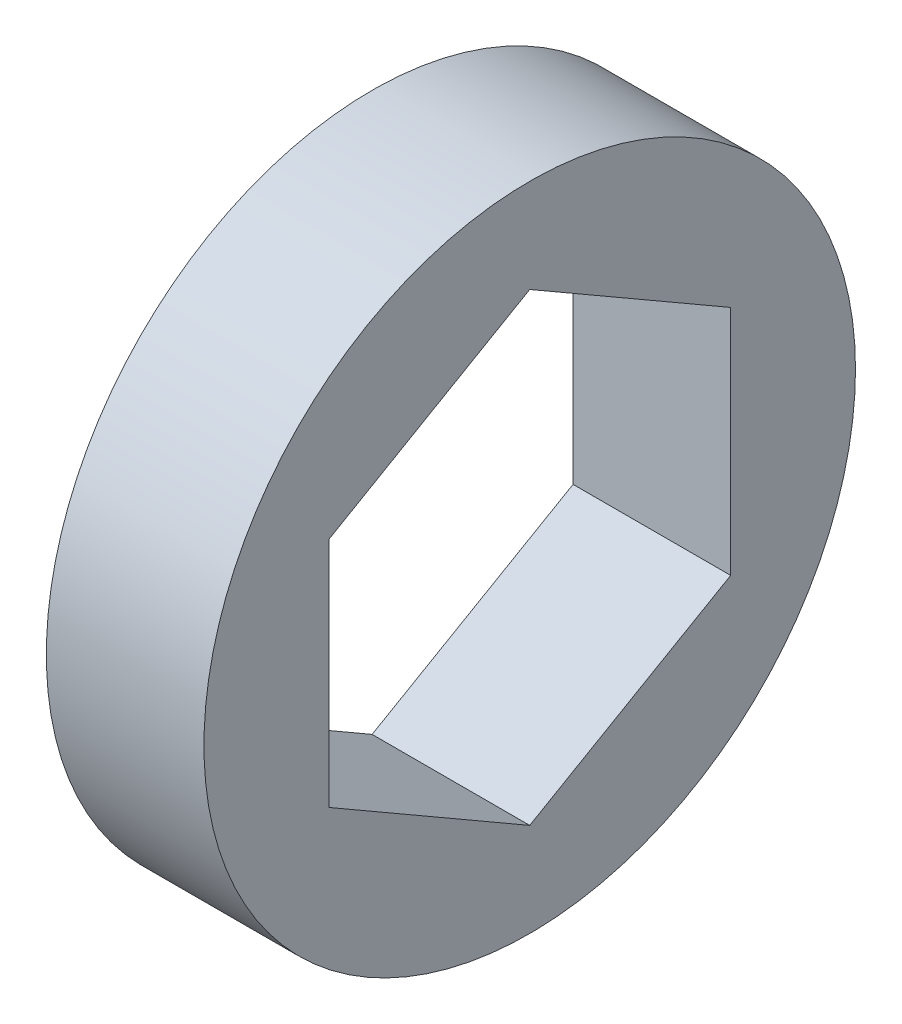
from build123d import *

# Parameters (mm, degrees)
SKETCH1_R           = 10.5
BOSS_EXTRUDE1_DEPTH = 5.08


with BuildPart() as part:
    # Sketch1 → Boss-Extrude1 (new body)
    with BuildSketch(Plane(origin=(0, 0, 0), x_dir=(0, 0, -1), z_dir=(1, 0, 0))):
        Circle(SKETCH1_R)
        Polygon((0, 7.478995387), (-6.477, 3.739497694), (-6.477, -3.739497694), (0, -7.478995387), (6.477, -3.739497694), (6.477, 3.739497694), align=None, mode=Mode.SUBTRACT)
    extrude(amount=BOSS_EXTRUDE1_DEPTH)


solid = part.part
